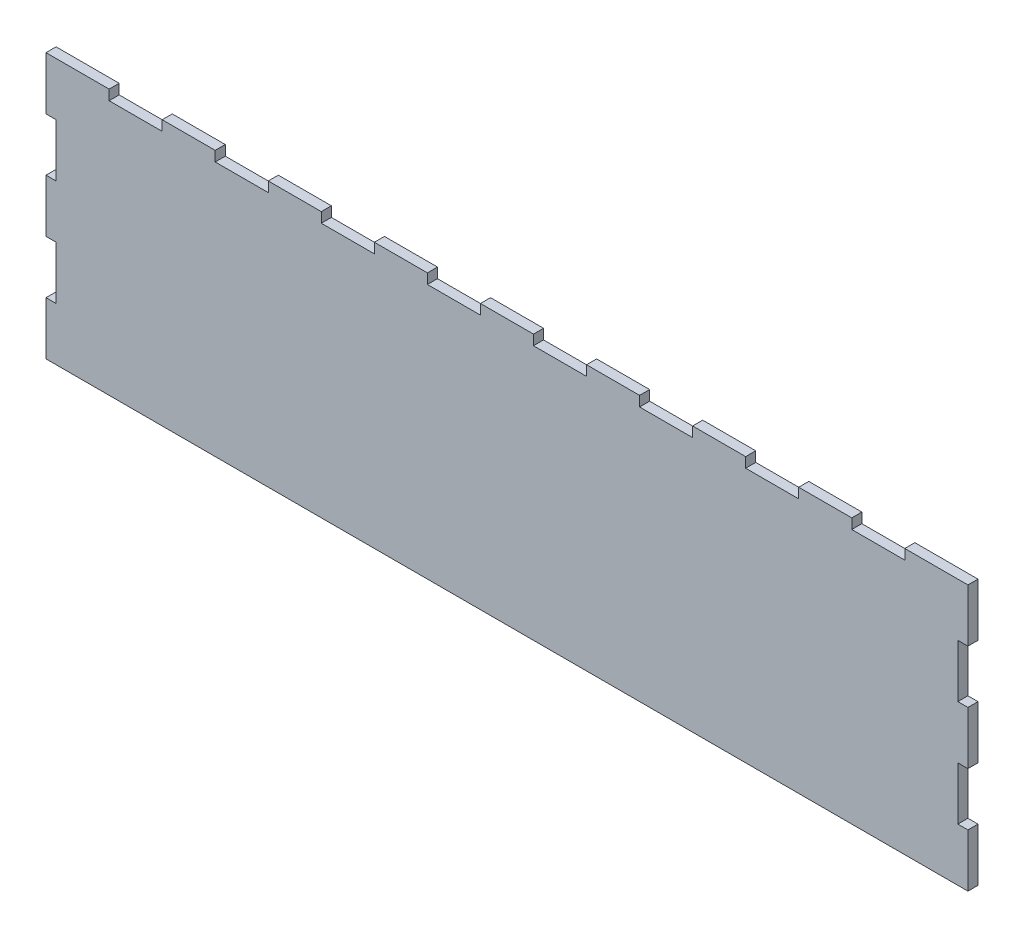
from build123d import *

# Parameters (mm, degrees)
BOSS_EXTRUDE1_DEPTH = 4.826
SKETCH2_W           = 25.4
SKETCH2_H           = 4.826
CUT_EXTRUDE1_DEPTH  = 4.826


with BuildPart() as part:
    # Sketch1 → Boss-Extrude1 (new body)
    with BuildSketch(Plane.XY):
        Polygon((95.25, 50.8), (95.25, 25.4), (90.424, 25.4), (90.424, 0), (95.25, 0), (527.05, 0), (531.876, 0), (531.876, 25.4), (527.05, 25.4), (527.05, 50.8), (531.876, 50.8), (531.876, 76.2), (527.05, 76.2), (527.05, 101.6), (531.876, 101.6), (531.876, 127), (90.424, 127), (90.424, 101.6), (95.25, 101.6), (95.25, 76.2), (90.424, 76.2), (90.424, 50.8), align=None)
    extrude(amount=BOSS_EXTRUDE1_DEPTH)

    # Sketch2 → Cut-Extrude1 (cut)
    with BuildSketch(Plane(origin=(0, 127, 0), x_dir=(1, 0, 0), z_dir=(0, 1, 0))):
        with Locations((133.35, -2.413)):
            Rectangle(SKETCH2_W, SKETCH2_H)
        with Locations((184.15, -2.413)):
            Rectangle(SKETCH2_W, SKETCH2_H)
        with Locations((234.95, -2.413)):
            Rectangle(SKETCH2_W, SKETCH2_H)
        with Locations((285.75, -2.413)):
            Rectangle(SKETCH2_W, SKETCH2_H)
        with Locations((336.55, -2.413)):
            Rectangle(SKETCH2_W, SKETCH2_H)
        with Locations((387.35, -2.413)):
            Rectangle(SKETCH2_W, SKETCH2_H)
        with Locations((438.15, -2.413)):
            Rectangle(SKETCH2_W, SKETCH2_H)
        with Locations((488.95, -2.413)):
            Rectangle(SKETCH2_W, SKETCH2_H)
    extrude(amount=-CUT_EXTRUDE1_DEPTH, mode=Mode.SUBTRACT)


solid = part.part
